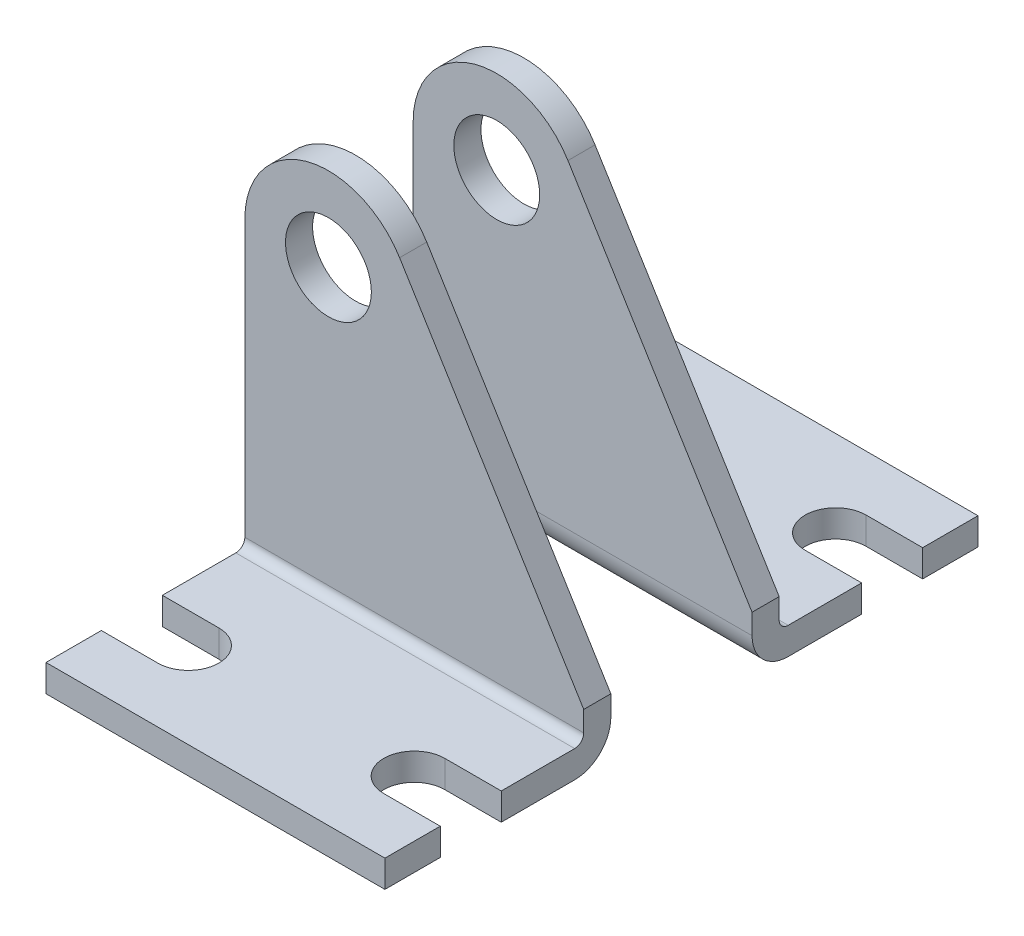
from build123d import *

# Parameters (mm, degrees)
SKETCH3_R           = 4.826
BOSS_EXTRUDE1_DEPTH = 3.048
SKETCH4_W           = 38.1
SKETCH4_H           = 3.048
BOSS_EXTRUDE2_DEPTH = 22.352
CUT_EXTRUDE1_DEPTH  = 4.048
FILLET1_R           = 1.016
FILLET2_R           = 4.064


with BuildPart() as part:
    # Sketch3 → Boss-Extrude1 (new body)
    with BuildSketch(Plane.XY):
        with BuildLine():
            Line((-9.398, 0), (-9.398, -35.052))
            Line((-9.398, -35.052), (28.702, -35.052))
            Line((28.702, -35.052), (28.702, -28.702))
            Line((28.702, -28.702), (8.003429206, 4.926207967))
            ThreePointArc((8.003429206, 4.926207967), (-2.559900029, 9.042638765), (-9.398, 0))
        make_face()
        Circle(SKETCH3_R, mode=Mode.SUBTRACT)
    extrude(amount=BOSS_EXTRUDE1_DEPTH)

    # Sketch4 → Boss-Extrude2 (add)
    with BuildSketch(Plane.XY.offset(3.048)):
        with Locations((9.652, -33.528)):
            Rectangle(SKETCH4_W, SKETCH4_H)
    extrude(amount=BOSS_EXTRUDE2_DEPTH)

    # Sketch5 → Cut-Extrude1 (cut, through all)
    with BuildSketch(Plane(origin=(0, -32.004, 0), x_dir=(1, 0, 0), z_dir=(0, 1, 0))):
        with BuildLine():
            Line((-3.048, -19.177), (-9.398, -19.177))
            Line((-9.398, -19.177), (-9.398, -12.319))
            Line((-9.398, -12.319), (-3.048, -12.319))
            ThreePointArc((-3.048, -12.319), (0.381, -15.748), (-3.048, -19.177))
        make_face()
        with BuildLine():
            Line((22.352, -12.319), (28.702, -12.319))
            Line((28.702, -12.319), (28.702, -19.177))
            Line((28.702, -19.177), (22.352, -19.177))
            ThreePointArc((22.352, -19.177), (18.923, -15.748), (22.352, -12.319))
        make_face()
    extrude(amount=-CUT_EXTRUDE1_DEPTH, mode=Mode.SUBTRACT)

    # Fillet1
    fillet1_edges = [part.edges().sort_by_distance(p)[0] for p in [
        (9.652, -32.004, 3.048),
    ]]
    fillet(fillet1_edges, radius=FILLET1_R)

    # Fillet2
    fillet2_edges = [part.edges().sort_by_distance(p)[0] for p in [
        (9.652, -35.052, 0),
    ]]
    fillet(fillet2_edges, radius=FILLET2_R)


with BuildPart() as body_2:
    # Mirror2: mirrored copy
    add(part.part.mirror(Plane.XY.offset(-7.9375)))


solid = Compound([part.part, body_2.part])
